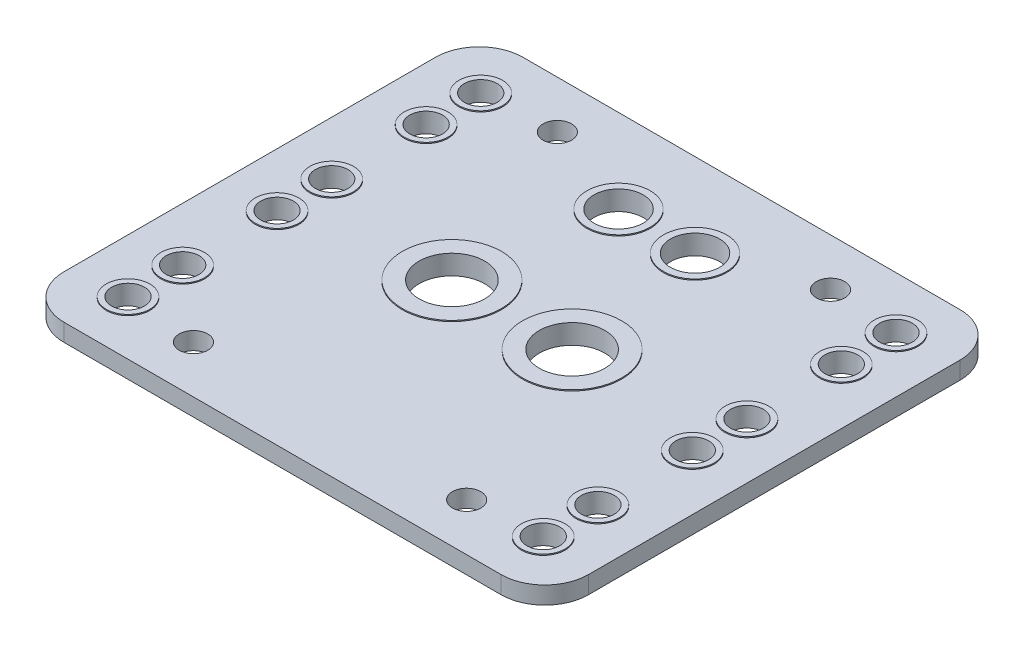
from build123d import *

# Parameters (mm, degrees)
SALIENTE_EXTRUIR1_DEPTH    = 0.8
CROQUIS2_R                 = 1.3
CORTAR_EXTRUIR1_DEPTH      = 1
CORTAR_EXTRUIR1_DEPTH_BACK = 2.6
CROQUIS3_R                 = 3
CORTAR_EXTRUIR2_DEPTH      = 2.6
CROQUIS5_R                 = 4.533685243
CROQUIS5_R_2               = 3
SALIENTE_EXTRUIR2_DEPTH    = 0.9
CROQUIS6_R                 = 2.25
CROQUIS6_R_2               = 1.5
CORTAR_EXTRUIR3_DEPTH      = 2.7
CROQUIS7_R                 = 2
CROQUIS7_R_2               = 1.5
CROQUIS7_R_3               = 2.894896359
CROQUIS7_R_4               = 2.25
SALIENTE_EXTRUIR3_DEPTH    = 0.9


with BuildPart() as part:
    # Croquis1 → Saliente-Extruir1 (new body, symmetric)
    with BuildSketch(Plane(origin=(0, 0, 0), x_dir=(1, 0, 0), z_dir=(0, 1, 0))):
        with BuildLine():
            Line((-20, 21), (20, 21))
            ThreePointArc((20, 21), (22.828427125, 19.828427125), (24, 17))
            Line((24, 17), (24, -17))
            ThreePointArc((24, -17), (22.828427125, -19.828427125), (20, -21))
            Line((20, -21), (-20, -21))
            ThreePointArc((-20, -21), (-22.828427125, -19.828427125), (-24, -17))
            Line((-24, -17), (-24, 17))
            ThreePointArc((-24, 17), (-22.828427125, 19.828427125), (-20, 21))
        make_face()
    extrude(amount=SALIENTE_EXTRUIR1_DEPTH, both=True)

    # Croquis2 → Cortar-Extruir1 (cut, two sides)
    with BuildSketch(Plane(origin=(0, 0.8, 0), x_dir=(1, 0, 0), z_dir=(0, 1, 0))) as cortar_extruir1_sk:
        with Locations((-12.5, 16.65)):
            Circle(CROQUIS2_R)
        with Locations((12.5, 16.65)):
            Circle(CROQUIS2_R)
        with Locations((12.5, -16.65)):
            Circle(CROQUIS2_R)
        with Locations((-12.5, -16.65)):
            Circle(CROQUIS2_R)
    extrude(amount=CORTAR_EXTRUIR1_DEPTH, mode=Mode.SUBTRACT)
    extrude(cortar_extruir1_sk.sketch, amount=-CORTAR_EXTRUIR1_DEPTH_BACK, mode=Mode.SUBTRACT)

    # Croquis3 → Cortar-Extruir2 (cut, through all)
    with BuildSketch(Plane(origin=(0, 0.8, 0), x_dir=(1, 0, 0), z_dir=(0, 1, 0))):
        with Locations((-5.5, 0)):
            Circle(CROQUIS3_R)
        with Locations((5.5, 0)):
            Circle(CROQUIS3_R)
    extrude(amount=-CORTAR_EXTRUIR2_DEPTH, mode=Mode.SUBTRACT)

    # Croquis5 → Saliente-Extruir2 (add, symmetric)
    with BuildSketch(Plane(origin=(0, 0, 0), x_dir=(1, 0, 0), z_dir=(0, 1, 0))):
        with Locations((-5.5, 0)):
            Circle(CROQUIS5_R)
        with Locations((-5.5, 0)):
            Circle(CROQUIS5_R_2, mode=Mode.SUBTRACT)
        with Locations((5.5, 0)):
            Circle(CROQUIS5_R)
        with Locations((5.5, 0)):
            Circle(CROQUIS5_R_2, mode=Mode.SUBTRACT)
    extrude(amount=SALIENTE_EXTRUIR2_DEPTH, both=True)

    # Croquis6 → Cortar-Extruir3 (cut, through all)
    with BuildSketch(Plane(origin=(0, 0.8, 0), x_dir=(1, 0, 0), z_dir=(0, 1, 0))):
        with Locations((-3.5, 13.25)):
            Circle(CROQUIS6_R)
        with Locations((3.5, 13.25)):
            Circle(CROQUIS6_R)
        with Locations((-19, 2.5)):
            Circle(CROQUIS6_R_2)
        with Locations((-19, -2.5)):
            Circle(CROQUIS6_R_2)
        with Locations((-19, 11.14)):
            Circle(CROQUIS6_R_2)
        with Locations((-19, 16.14)):
            Circle(CROQUIS6_R_2)
        with Locations((-19, -11.14)):
            Circle(CROQUIS6_R_2)
        with Locations((-19, -16.14)):
            Circle(CROQUIS6_R_2)
        with Locations((19, -16.14)):
            Circle(CROQUIS6_R_2)
        with Locations((19, -11.14)):
            Circle(CROQUIS6_R_2)
        with Locations((19, 16.14)):
            Circle(CROQUIS6_R_2)
        with Locations((19, 11.14)):
            Circle(CROQUIS6_R_2)
        with Locations((19, -2.5)):
            Circle(CROQUIS6_R_2)
        with Locations((19, 2.5)):
            Circle(CROQUIS6_R_2)
    extrude(amount=-CORTAR_EXTRUIR3_DEPTH, mode=Mode.SUBTRACT)

    # Croquis7 → Saliente-Extruir3 (add, symmetric)
    with BuildSketch(Plane(origin=(0, 0, 0), x_dir=(1, 0, 0), z_dir=(0, 1, 0))):
        with Locations((-19, 16.14)):
            Circle(CROQUIS7_R)
        with Locations((-19, 16.14)):
            Circle(CROQUIS7_R_2, mode=Mode.SUBTRACT)
        with Locations((-19, 11.14)):
            Circle(CROQUIS7_R)
        with Locations((-19, 11.14)):
            Circle(CROQUIS7_R_2, mode=Mode.SUBTRACT)
        with Locations((-19, 2.5)):
            Circle(CROQUIS7_R)
        with Locations((-19, 2.5)):
            Circle(CROQUIS7_R_2, mode=Mode.SUBTRACT)
        with Locations((-19, -2.5)):
            Circle(CROQUIS7_R)
        with Locations((-19, -2.5)):
            Circle(CROQUIS7_R_2, mode=Mode.SUBTRACT)
        with Locations((-19, -16.14)):
            Circle(CROQUIS7_R)
        with Locations((-19, -16.14)):
            Circle(CROQUIS7_R_2, mode=Mode.SUBTRACT)
        with Locations((-19, -11.14)):
            Circle(CROQUIS7_R)
        with Locations((-19, -11.14)):
            Circle(CROQUIS7_R_2, mode=Mode.SUBTRACT)
        with Locations((-3.5, 13.25)):
            Circle(CROQUIS7_R_3)
        with Locations((-3.5, 13.25)):
            Circle(CROQUIS7_R_4, mode=Mode.SUBTRACT)
        with Locations((3.5, 13.25)):
            Circle(CROQUIS7_R_3)
        with Locations((3.5, 13.25)):
            Circle(CROQUIS7_R_4, mode=Mode.SUBTRACT)
        with Locations((19, -11.14)):
            Circle(CROQUIS7_R)
        with Locations((19, -11.14)):
            Circle(CROQUIS7_R_2, mode=Mode.SUBTRACT)
        with Locations((19, -16.14)):
            Circle(CROQUIS7_R)
        with Locations((19, -16.14)):
            Circle(CROQUIS7_R_2, mode=Mode.SUBTRACT)
        with Locations((19, -2.5)):
            Circle(CROQUIS7_R)
        with Locations((19, -2.5)):
            Circle(CROQUIS7_R_2, mode=Mode.SUBTRACT)
        with Locations((19, 2.5)):
            Circle(CROQUIS7_R)
        with Locations((19, 2.5)):
            Circle(CROQUIS7_R_2, mode=Mode.SUBTRACT)
        with Locations((19, 11.14)):
            Circle(CROQUIS7_R)
        with Locations((19, 11.14)):
            Circle(CROQUIS7_R_2, mode=Mode.SUBTRACT)
        with Locations((19, 16.14)):
            Circle(CROQUIS7_R)
        with Locations((19, 16.14)):
            Circle(CROQUIS7_R_2, mode=Mode.SUBTRACT)
    extrude(amount=SALIENTE_EXTRUIR3_DEPTH, both=True)


solid = part.part
